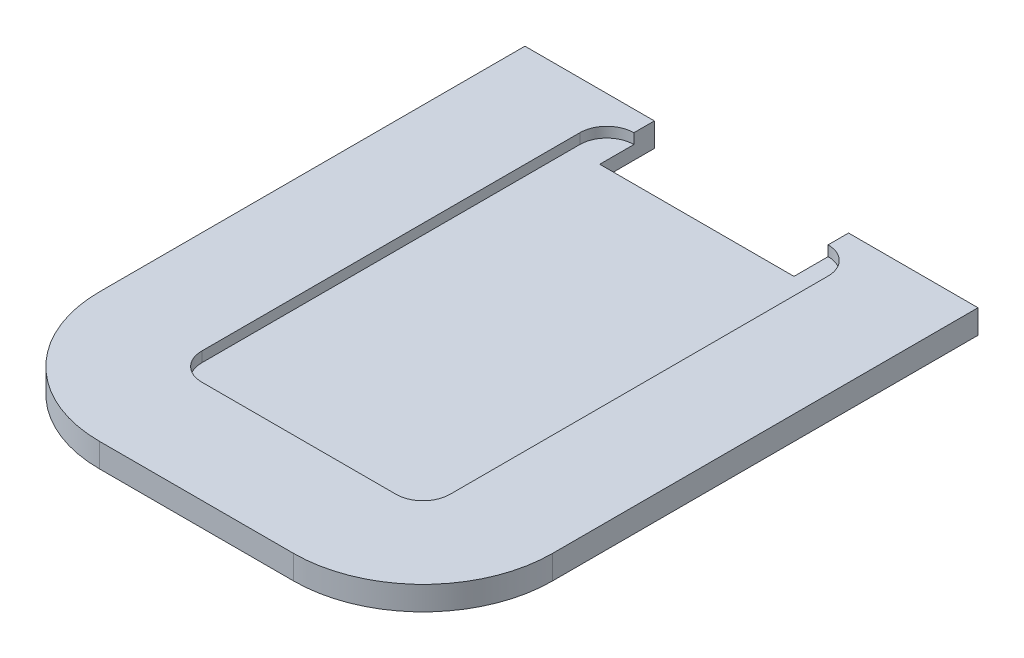
from build123d import *

# Parameters (mm, degrees)
BOSS_EXTRUDE1_DEPTH = 2
BOSS_EXTRUDE4_DEPTH = 1.5
SKETCH4_W           = 18.96
SKETCH4_H           = 3
BOSS_EXTRUDE5_DEPTH = 3.5


with BuildPart() as part:
    # Sketch1 → Boss-Extrude1 (new body)
    with BuildSketch(Plane.XZ.offset(-30.427346286)):
        with BuildLine():
            Line((61.676013052, 15.196320566), (61.676013052, 19.156320566))
            Line((61.676013052, 19.156320566), (61.676013052, 74.528320566))
            ThreePointArc((61.676013052, 74.528320566), (56.122757624, 87.935065137), (42.716013052, 93.488320566))
            Line((42.716013052, 93.488320566), (14.268013052, 93.488320566))
            ThreePointArc((14.268013052, 93.488320566), (0.861268481, 87.935065137), (-4.691986948, 74.528320566))
            Line((-4.691986948, 74.528320566), (-4.691986948, 19.156320566))
            Line((-4.691986948, 19.156320566), (-4.691986948, 15.196320566))
            Line((-4.691986948, 15.196320566), (-4.273831516, 15.196320566))
            Line((-4.273831516, 15.196320566), (14.268013052, 15.196320566))
            Line((14.268013052, 15.196320566), (14.268013052, 20.196320566))
            Line((14.268013052, 20.196320566), (42.716013052, 20.196320566))
            Line((42.716013052, 20.196320566), (42.716013052, 15.196320566))
            Line((42.716013052, 15.196320566), (61.257857621, 15.196320566))
            Line((61.257857621, 15.196320566), (61.676013052, 15.196320566))
        make_face()
    extrude(amount=BOSS_EXTRUDE1_DEPTH)

    # Sketch3 → Boss-Extrude4 (add)
    with BuildSketch(Plane(origin=(0, 30.427346286, 0), x_dir=(1, 0, 0), z_dir=(0, 1, 0))):
        with BuildLine():
            ThreePointArc((46.676013052, -19.156320566), (45.516155906, -16.356177712), (42.716013052, -15.196320566))
            Line((42.716013052, -15.196320566), (61.676013052, -15.196320566))
            Line((61.676013052, -15.196320566), (61.676013052, -74.528320566))
            ThreePointArc((61.676013052, -74.528320566), (56.122757624, -87.935065137), (42.716013052, -93.488320566))
            Line((42.716013052, -93.488320566), (14.268013052, -93.488320566))
            ThreePointArc((14.268013052, -93.488320566), (0.861268481, -87.935065137), (-4.691986948, -74.528320566))
            Line((-4.691986948, -74.528320566), (-4.691986948, -15.196320566))
            Line((-4.691986948, -15.196320566), (14.268013052, -15.196320566))
            ThreePointArc((14.268013052, -15.196320566), (11.467870199, -16.356177712), (10.308013052, -19.156320566))
            Line((10.308013052, -19.156320566), (10.308013052, -74.528320566))
            ThreePointArc((10.308013052, -74.528320566), (11.467870199, -77.328463419), (14.268013052, -78.488320566))
            Line((14.268013052, -78.488320566), (42.716013052, -78.488320566))
            ThreePointArc((42.716013052, -78.488320566), (45.516155906, -77.328463419), (46.676013052, -74.528320566))
            Line((46.676013052, -74.528320566), (46.676013052, -19.156320566))
        make_face()
    extrude(amount=BOSS_EXTRUDE4_DEPTH)

    # Sketch4 → Boss-Extrude5 (add)
    with BuildSketch(Plane.XZ.offset(-28.427346286)):
        with Locations((4.788013052, 13.696320566)):
            Rectangle(SKETCH4_W, SKETCH4_H)
        with Locations((52.196013052, 13.696320566)):
            Rectangle(SKETCH4_W, SKETCH4_H)
    extrude(amount=-BOSS_EXTRUDE5_DEPTH)


solid = part.part
